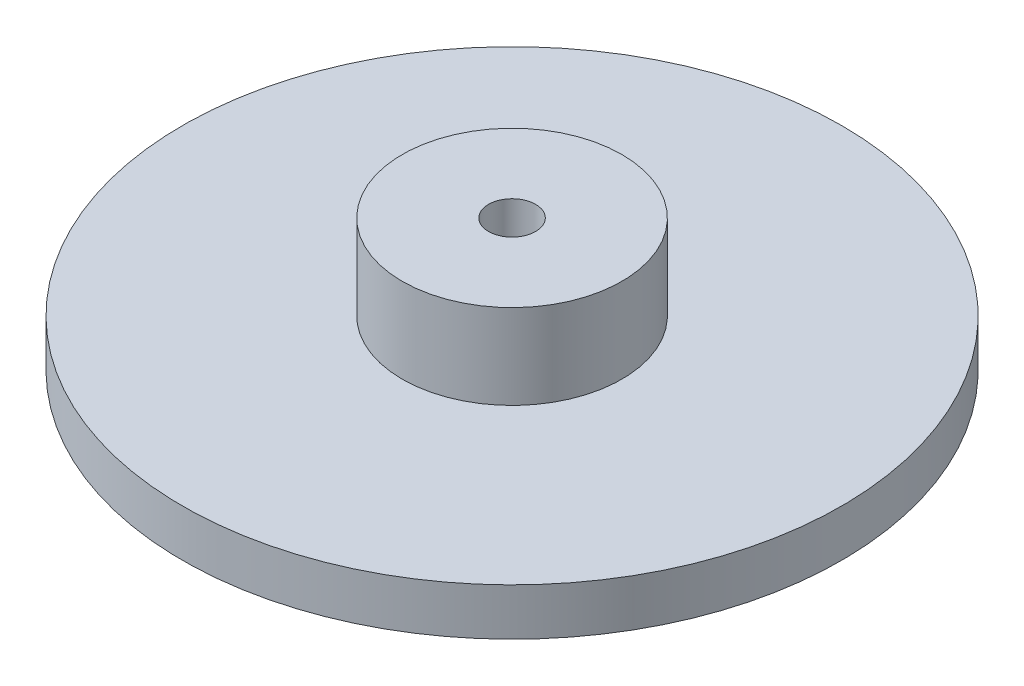
from build123d import *

# Parameters (mm, degrees)
ESQUISSE2_R             = 1.5
ENL_V_MAT_EXTRU_1_DEPTH = 9.4


with BuildPart() as part:
    # Esquisse1 → Révolution1 (revolve)
    with BuildSketch(Plane.XY):
        Polygon((0, 0), (0, 8.4), (7, 8.4), (7, 3), (21, 3), (21, 0), align=None)
    revolve(axis=Axis((0, 0, 0), (0, 1, 0)))

    # Esquisse2 → Enlèv. mat.-Extru.1 (cut, through all)
    with BuildSketch(Plane(origin=(0, 8.4, 0), x_dir=(1, 0, 0), z_dir=(0, 1, 0))):
        Circle(ESQUISSE2_R)
    extrude(amount=-ENL_V_MAT_EXTRU_1_DEPTH, mode=Mode.SUBTRACT)


solid = part.part
